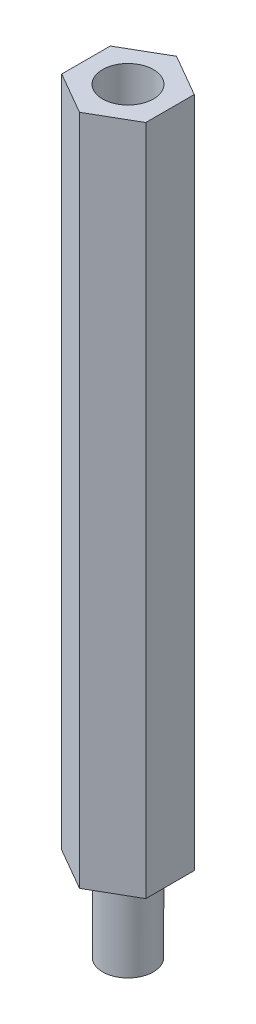
from build123d import *

# Parameters (mm, degrees)
BOSS_EXTRUDE1_DEPTH = 40
SKETCH2_R           = 1.516102493
CUT_EXTRUDE1_DEPTH  = 10
SKETCH3_R           = 1.505855903
BOSS_EXTRUDE2_DEPTH = 5


with BuildPart() as part:
    # Sketch1 → Boss-Extrude1 (new body)
    with BuildSketch(Plane(origin=(0, 0, 0), x_dir=(1, 0, 0), z_dir=(0, 1, 0))):
        Polygon((0, -2.886751346), (2.5, -1.443375673), (2.5, 1.443375673), (0, 2.886751346), (-2.5, 1.443375673), (-2.5, -1.443375673), align=None)
    extrude(amount=BOSS_EXTRUDE1_DEPTH)

    # Sketch2 → Cut-Extrude1 (cut)
    with BuildSketch(Plane(origin=(0, 40, 0), x_dir=(1, 0, 0), z_dir=(0, 1, 0))):
        Circle(SKETCH2_R)
    extrude(amount=-CUT_EXTRUDE1_DEPTH, mode=Mode.SUBTRACT)

    # Sketch3 → Boss-Extrude2 (add)
    with BuildSketch(Plane.XZ):
        Circle(SKETCH3_R)
    extrude(amount=BOSS_EXTRUDE2_DEPTH)


solid = part.part
